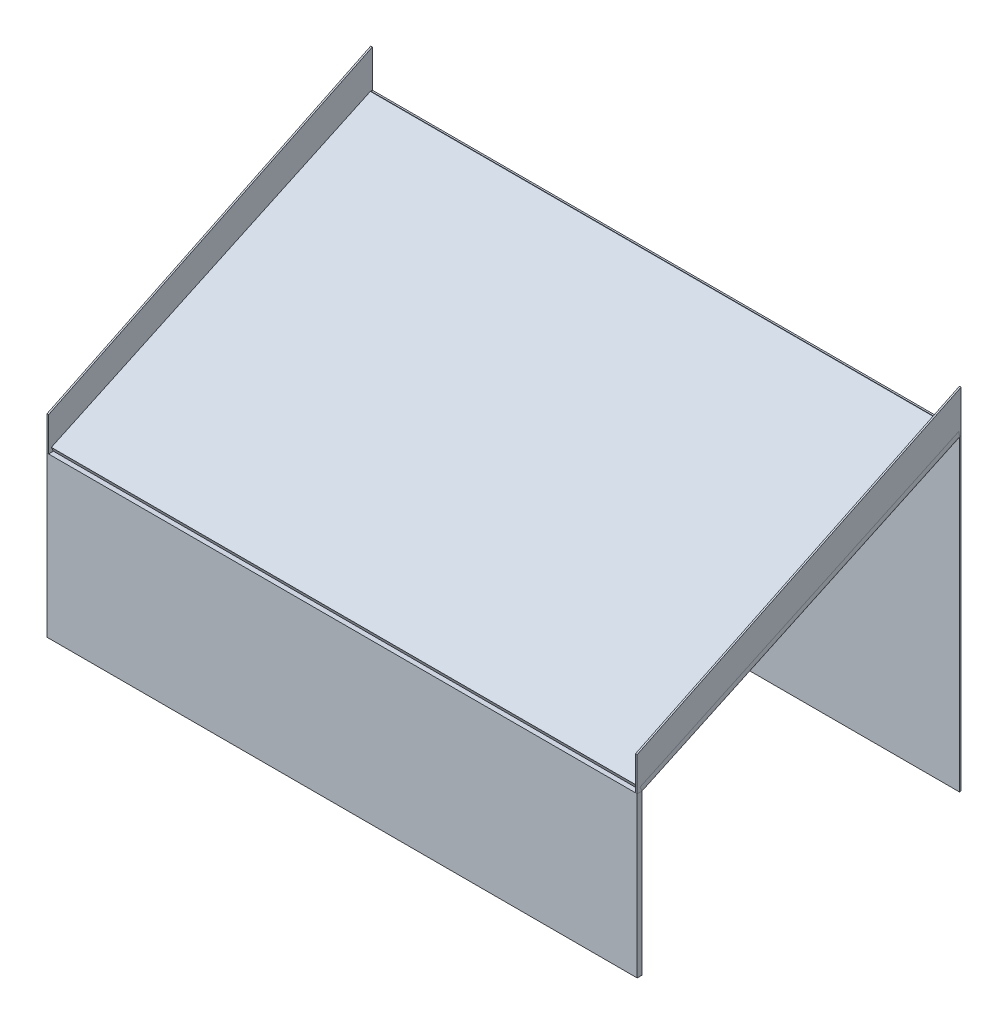
from build123d import *

# Parameters (mm, degrees)
SKETCH1_W             = 3
SKETCH1_H             = 200
BOSS_EXTRUDE1_DEPTH   = 100
BOSS_EXTRUDE1_2_DEPTH = 100
BOSS_EXTRUDE2_DEPTH   = 3
SKETCH3_W             = 370
SKETCH3_H             = 100
BOSS_EXTRUDE3_DEPTH   = 3
BOSS_EXTRUDE4_DEPTH   = 3
SKETCH5_W             = 370
SKETCH5_H             = 220.675583793
BOSS_EXTRUDE7_DEPTH   = 3
CUT_EXTRUDE2_DEPTH    = 371
SKETCH7_W             = 370
SKETCH7_H             = 195.980454992
BOSS_EXTRUDE8_DEPTH   = 1
BOSS_EXTRUDE10_DEPTH  = 1
BOSS_EXTRUDE12_DEPTH  = 1


with BuildPart() as part:
    # Sketch1 → Boss-Extrude1 (new body)
    with BuildSketch(Plane(origin=(0, 0, 0), x_dir=(1, 0, 0), z_dir=(0, 1, 0))):
        with Locations((-183.5, 0)):
            Rectangle(SKETCH1_W, SKETCH1_H)
    extrude(amount=BOSS_EXTRUDE1_DEPTH)



with BuildPart() as body_2:
    # Sketch1 → Boss-Extrude1 2 (new body)
    with BuildSketch(Plane(origin=(0, 0, 0), x_dir=(1, 0, 0), z_dir=(0, 1, 0))):
        with Locations((183.5, 0)):
            Rectangle(SKETCH1_W, SKETCH1_H)
    extrude(amount=BOSS_EXTRUDE1_2_DEPTH)

    # Sketch2 → Boss-Extrude2 (add)
    with BuildSketch(Plane(origin=(185, 0, 0), x_dir=(0, 0, -1), z_dir=(1, 0, 0))):
        Polygon((-100, 100), (100, 100), (100, 193.261531631), align=None)
    extrude(amount=-BOSS_EXTRUDE2_DEPTH)


with BuildPart() as part_1:
    add(part.part)

    add(body_2.part)  # Boss-Extrude3 merges body 2
    # Sketch3 → Boss-Extrude3 (add)
    with BuildSketch(Plane.XY.offset(100)):
        with Locations((0, 50)):
            Rectangle(SKETCH3_W, SKETCH3_H)
    extrude(amount=BOSS_EXTRUDE3_DEPTH)

    # Sketch4 → Boss-Extrude4 (add)
    with BuildSketch(Plane.ZY.offset(185)):
        Polygon((-100, 100), (-100, 193.261531631), (100, 100), align=None)
    extrude(amount=-BOSS_EXTRUDE4_DEPTH)

    # Sketch6 → Cut-Extrude2 (cut, through all)
    with BuildSketch(Plane(origin=(185, 0, 0), x_dir=(0, 0, -1), z_dir=(1, 0, 0))):
        Polygon((100, 193.261531631), (-100, 100), (-100, 0), (100, 0), align=None)
    extrude(amount=-CUT_EXTRUDE2_DEPTH, mode=Mode.SUBTRACT)


with BuildPart() as body_2_2:
    # Sketch5 → Boss-Extrude7 (new body)
    with BuildSketch(Plane(origin=(0, 120.44160264, 56.162841672), x_dir=(1, 0, 0), z_dir=(0, 0.906307787, 0.422618262))):
        with Locations((0, 61.968839367)):
            Rectangle(SKETCH5_W, SKETCH5_H)
    extrude(amount=BOSS_EXTRUDE7_DEPTH)

    # Sketch7 → Boss-Extrude8 (add)
    with BuildSketch(Plane(origin=(0, 0, -100), x_dir=(-1, 0, 0), z_dir=(0, 0, -1))):
        with Locations((0, 97.990227496)):
            Rectangle(SKETCH7_W, SKETCH7_H)
    extrude(amount=-BOSS_EXTRUDE8_DEPTH)


with BuildPart() as body_3:
    # Sketch8 → Boss-Extrude10 (new body)
    with BuildSketch(Plane(origin=(185, 0, 0), x_dir=(0, 0, -1), z_dir=(1, 0, 0))):
        Polygon((-103, 100), (-103, 121.325535705), (100, 219.253762877), (100, 193.084600163), (-100, 100), align=None)
    extrude(amount=-BOSS_EXTRUDE10_DEPTH)


with BuildPart() as body_4:
    # Sketch9 → Boss-Extrude12 (new body)
    with BuildSketch(Plane.ZY.offset(185)):
        Polygon((103, 100), (100, 100), (-100, 193.084600163), (-100, 219.473902), (103, 121.325535705), align=None)
    extrude(amount=-BOSS_EXTRUDE12_DEPTH)


solid = Compound([part_1.part, body_2_2.part, body_3.part, body_4.part])
